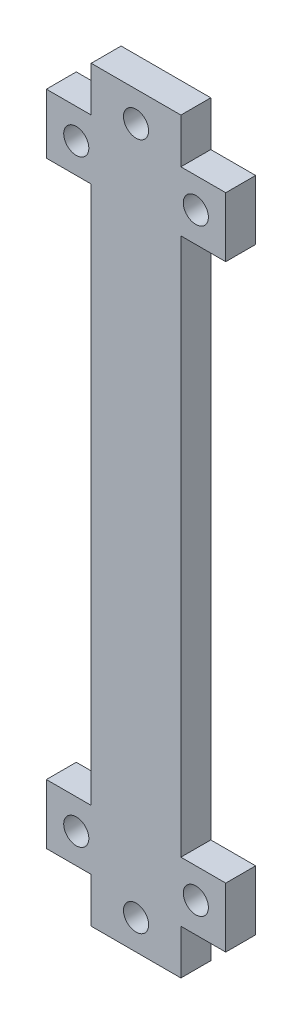
from build123d import *

# Parameters (mm, degrees)
SKETCH1_W           = 15
SKETCH1_H           = 90
SKETCH1_R           = 2.1
SKETCH1_H_2         = 7.5
BOSS_EXTRUDE1_DEPTH = 5


with BuildPart() as part:
    # Sketch1 → Boss-Extrude1 (new body)
    with BuildSketch(Plane.XY):
        with Locations((7.5, 45)):
            Rectangle(SKETCH1_W, SKETCH1_H)
        Polygon((-7.5, 90), (0, 90), (15, 90), (22.5, 90), (22.5, 100), (15, 100), (0, 100), (-7.5, 100), align=None)
        with Locations((-2.5, 95)):
            Circle(SKETCH1_R, mode=Mode.SUBTRACT)
        with Locations((17.5, 95)):
            Circle(SKETCH1_R, mode=Mode.SUBTRACT)
        with Locations((7.5, 103.75)):
            Rectangle(SKETCH1_W, SKETCH1_H_2)
        with Locations((7.5, 102.5)):
            Circle(SKETCH1_R, mode=Mode.SUBTRACT)
        Polygon((15, 0), (0, 0), (-7.5, 0), (-7.5, -10), (0, -10), (15, -10), (22.5, -10), (22.5, 0), align=None)
        with Locations((-2.5, -5)):
            Circle(SKETCH1_R, mode=Mode.SUBTRACT)
        with Locations((17.5, -5)):
            Circle(SKETCH1_R, mode=Mode.SUBTRACT)
        with Locations((7.5, -13.75)):
            Rectangle(SKETCH1_W, SKETCH1_H_2)
        with Locations((7.5, -12.5)):
            Circle(SKETCH1_R, mode=Mode.SUBTRACT)
    extrude(amount=BOSS_EXTRUDE1_DEPTH)


solid = part.part
